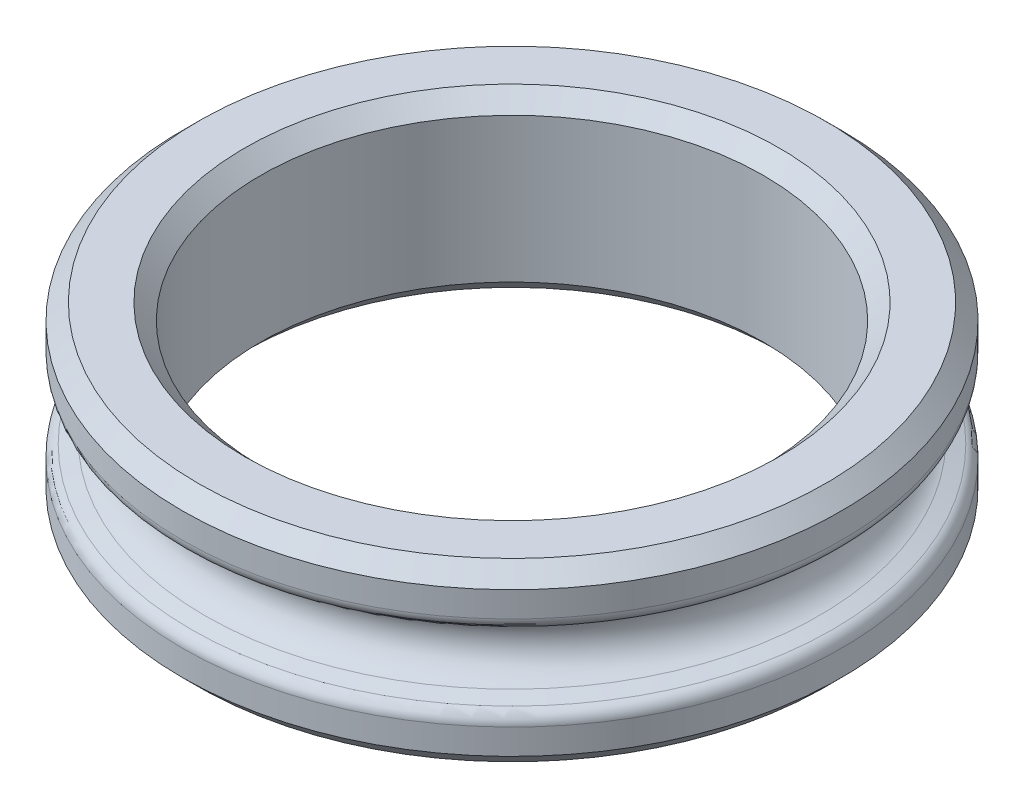
from build123d import *

# Parameters (mm, degrees)
CHAMFER1_SIZE = 0.25
FILLET1_R     = 0.2


with BuildPart() as part:
    # Sketch1 → Revolve1 (revolve)
    with BuildSketch(Plane.XY):
        with BuildLine():
            Line((3.96875, 1.3890625), (3.96875, -1.3890625))
            Line((3.96875, -1.3890625), (5.2, -1.3890625))
            Line((5.2, -1.3890625), (5.2, -0.594165218))
            Line((5.2, -0.594165218), (4.841347672, -0.474161828))
            ThreePointArc((4.841347672, -0.474161828), (4.5, 0), (4.841347672, 0.474161828))
            Line((4.841347672, 0.474161828), (5.2, 0.594165218))
            Line((5.2, 0.594165218), (5.2, 1.3890625))
            Line((5.2, 1.3890625), (3.96875, 1.3890625))
        make_face()
    revolve(axis=Axis((0, 0, 0), (0, 1, 0)))

    # Chamfer1
    chamfer1_edges = [part.edges().sort_by_distance(p)[0] for p in [
        (-3.96875, 1.3890625, 0),
        (-5.2, 1.3890625, 0),
        (-5.2, -1.3890625, 0),
        (-3.96875, -1.3890625, 0),
    ]]
    chamfer(chamfer1_edges, length=CHAMFER1_SIZE)

    # Fillet1
    fillet1_edges = [part.edges().sort_by_distance(p)[0] for p in [
        (-5.2, 0.594165218, 0),
        (-5.2, -0.594165218, 0),
    ]]
    fillet(fillet1_edges, radius=FILLET1_R)


solid = part.part
